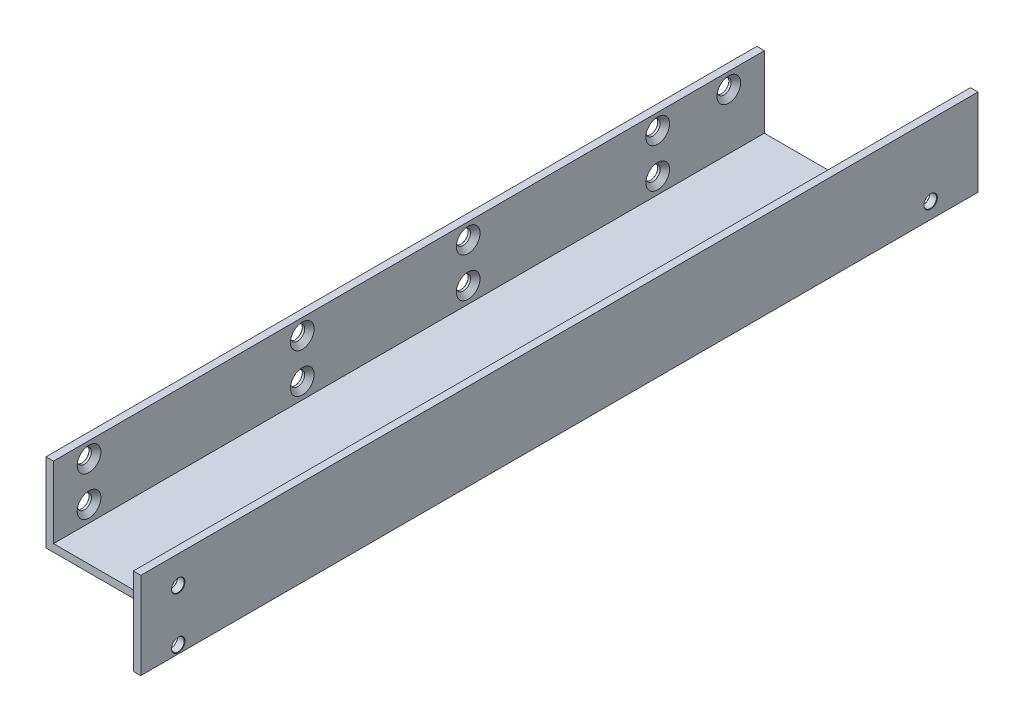
from build123d import *

# Parameters (mm, degrees)
EXTRUDE_1_DEPTH              = 212
SKETCH_2_W                   = 38.1
SKETCH_2_H                   = 16
CUT_EXTRUDE_1_DEPTH          = 23
HOLE_WIZARD_M31_AT_2_COUNT   = 2
HOLE_WIZARD_M31_AT_2_PITCH   = 48
HOLE_WIZARD_M31_AT_3_COUNT   = 2
HOLE_WIZARD_M31_AT_3_PITCH   = 66.753277073
HOLE_WIZARD_M31_AT_4_COUNT   = 2
HOLE_WIZARD_M31_AT_4_PITCH   = 42
HOLE_WIZARD_M31_AT_5_COUNT   = 2
HOLE_WIZARD_M31_AT_5_PITCH   = 43.17406629
HOLE_WIZARD_M31_AT_6_COUNT   = 2
HOLE_WIZARD_M31_AT_6_PITCH   = 96.519428096
HOLE_WIZARD_M31_AT_7_COUNT   = 2
HOLE_WIZARD_M31_AT_7_PITCH   = 96
HOLE_WIZARD_M31_AT_8_COUNT   = 2
HOLE_WIZARD_M31_AT_8_PITCH   = 10
HOLE_WIZARD_M31_AT_9_COUNT   = 2
HOLE_WIZARD_M31_AT_9_PITCH   = 49.030602689
HOLE_WIZARD_M31_2_AT_2_COUNT = 2
HOLE_WIZARD_M31_2_AT_2_PITCH = 13
HOLE_WIZARD_M31_2_AT_3_COUNT = 2
HOLE_WIZARD_M31_2_AT_3_PITCH = 190.510498398
HOLE_WIZARD_M32_AT_2_COUNT   = 2
HOLE_WIZARD_M32_AT_2_PITCH   = 50
HOLE_WIZARD_M32_AT_3_COUNT   = 2
HOLE_WIZARD_M32_AT_3_PITCH   = 110
HOLE_WIZARD_M32_AT_4_COUNT   = 2
HOLE_WIZARD_M32_AT_4_PITCH   = 160


with BuildPart() as part:
    # Эскиз1 → Бобышка-Вытянуть1 (new body)
    with BuildSketch(Plane.XY):
        Polygon((-20, 20), (-20, 0), (20, 0), (20, 22), (18.1, 22), (18.1, 1.9), (-18.1, 1.9), (-18.1, 20), align=None)
    extrude(amount=EXTRUDE_1_DEPTH)

    # Эскиз2 → Вырез-Вытянуть1 (cut, through all)
    with BuildSketch(Plane(origin=(0, 0, 0), x_dir=(1, 0, 0), z_dir=(0, 1, 0))):
        with Locations((-0.95, -204)):
            Rectangle(SKETCH_2_W, SKETCH_2_H)
        with Locations((-0.95, -8)):
            Rectangle(SKETCH_2_W, SKETCH_2_H)
    extrude(amount=CUT_EXTRUDE_1_DEPTH, mode=Mode.SUBTRACT)

    # Эскиз4 → Hole Wizard M31 (revolve, cut)
    with BuildSketch(Plane(origin=(-18.1, 6, 91), x_dir=(0, 0, -1), z_dir=(0, 1, 0))):
        Polygon((0, 0), (0, 1.9), (1.9, 1.9), (1.8, 1.8), (1.8, 1.2), (3, 0), align=None)
    hole_wizard_m31 = revolve(axis=Axis((-11.75, 6, 91), (-1, 0, 0)), mode=Mode.SUBTRACT)

    # Hole Wizard M31 at 2: Hole Wizard M31 ×2
    with Locations(*[(0, 0, -i * HOLE_WIZARD_M31_AT_2_PITCH) for i in range(1, HOLE_WIZARD_M31_AT_2_COUNT)]):
        add(hole_wizard_m31, mode=Mode.SUBTRACT)

    # Hole Wizard M31 at 3: Hole Wizard M31 ×2
    with Locations(*[Vector(0, 0.149805379, -0.988715504) * (i * HOLE_WIZARD_M31_AT_3_PITCH) for i in range(1, HOLE_WIZARD_M31_AT_3_COUNT)]):
        add(hole_wizard_m31, mode=Mode.SUBTRACT)

    # Hole Wizard M31 at 4: Hole Wizard M31 ×2
    with Locations(*[(0, 0, i * HOLE_WIZARD_M31_AT_4_PITCH) for i in range(1, HOLE_WIZARD_M31_AT_4_COUNT)]):
        add(hole_wizard_m31, mode=Mode.SUBTRACT)

    # Hole Wizard M31 at 5: Hole Wizard M31 ×2
    with Locations(*[Vector(0, 0.231620527, 0.972806215) * (i * HOLE_WIZARD_M31_AT_5_PITCH) for i in range(1, HOLE_WIZARD_M31_AT_5_COUNT)]):
        add(hole_wizard_m31, mode=Mode.SUBTRACT)

    # Hole Wizard M31 at 6: Hole Wizard M31 ×2
    with Locations(*[Vector(0, 0.103606084, 0.994618409) * (i * HOLE_WIZARD_M31_AT_6_PITCH) for i in range(1, HOLE_WIZARD_M31_AT_6_COUNT)]):
        add(hole_wizard_m31, mode=Mode.SUBTRACT)

    # Hole Wizard M31 at 7: Hole Wizard M31 ×2
    with Locations(*[(0, 0, i * HOLE_WIZARD_M31_AT_7_PITCH) for i in range(1, HOLE_WIZARD_M31_AT_7_COUNT)]):
        add(hole_wizard_m31, mode=Mode.SUBTRACT)

    # Hole Wizard M31 at 8: Hole Wizard M31 ×2
    with Locations(*[(0, i * HOLE_WIZARD_M31_AT_8_PITCH, 0) for i in range(1, HOLE_WIZARD_M31_AT_8_COUNT)]):
        add(hole_wizard_m31, mode=Mode.SUBTRACT)

    # Hole Wizard M31 at 9: Hole Wizard M31 ×2
    with Locations(*[Vector(0, 0.203954254, -0.97898042) * (i * HOLE_WIZARD_M31_AT_9_PITCH) for i in range(1, HOLE_WIZARD_M31_AT_9_COUNT)]):
        add(hole_wizard_m31, mode=Mode.SUBTRACT)

    # Эскиз7 → Hole Wizard M31 2 (revolve, cut)
    with BuildSketch(Plane(origin=(20, 2, 202.5), x_dir=(0, 0, -1), z_dir=(0, 1, 0))):
        Polygon((0, 0), (0, 1.9), (1.7, 1.9), (1.6, 1.8), (1.6, 0.1), (1.7, 0), align=None)
    hole_wizard_m31_2 = revolve(axis=Axis((26.35, 2, 202.5), (-1, 0, 0)), mode=Mode.SUBTRACT)

    # Hole Wizard M31 2 at 2: Hole Wizard M31 2 ×2
    with Locations(*[(0, i * HOLE_WIZARD_M31_2_AT_2_PITCH, 0) for i in range(1, HOLE_WIZARD_M31_2_AT_2_COUNT)]):
        add(hole_wizard_m31_2, mode=Mode.SUBTRACT)

    # Hole Wizard M31 2 at 3: Hole Wizard M31 2 ×2
    with Locations(*[Vector(0, 0.010498109, -0.999944893) * (i * HOLE_WIZARD_M31_2_AT_3_PITCH) for i in range(1, HOLE_WIZARD_M31_2_AT_3_COUNT)]):
        add(hole_wizard_m31_2, mode=Mode.SUBTRACT)

    # Эскиз9 → Зенковка для винта с потайной головкой M32 (revolve, cut)
    with BuildSketch(Plane(origin=(12.2, 1.9, 186), x_dir=(0, 0, 1), z_dir=(1, 0, 0))):
        Polygon((0, 0), (0, 1.9), (1.9, 1.9), (1.8, 1.8), (1.8, 1.2), (3, 0), align=None)
    hole_wizard_m32 = revolve(axis=Axis((12.2, 8.25, 186), (0, -1, 0)), mode=Mode.SUBTRACT)

    # Зенковка для винта с потайной головкой M32 at 2: Зенковка для винта с потайной головкой M32 ×2
    with Locations(*[(0, 0, -i * HOLE_WIZARD_M32_AT_2_PITCH) for i in range(1, HOLE_WIZARD_M32_AT_2_COUNT)]):
        add(hole_wizard_m32, mode=Mode.SUBTRACT)

    # Зенковка для винта с потайной головкой M32 at 3: Зенковка для винта с потайной головкой M32 ×2
    with Locations(*[(0, 0, -i * HOLE_WIZARD_M32_AT_3_PITCH) for i in range(1, HOLE_WIZARD_M32_AT_3_COUNT)]):
        add(hole_wizard_m32, mode=Mode.SUBTRACT)

    # Зенковка для винта с потайной головкой M32 at 4: Зенковка для винта с потайной головкой M32 ×2
    with Locations(*[(0, 0, -i * HOLE_WIZARD_M32_AT_4_PITCH) for i in range(1, HOLE_WIZARD_M32_AT_4_COUNT)]):
        add(hole_wizard_m32, mode=Mode.SUBTRACT)


solid = part.part
